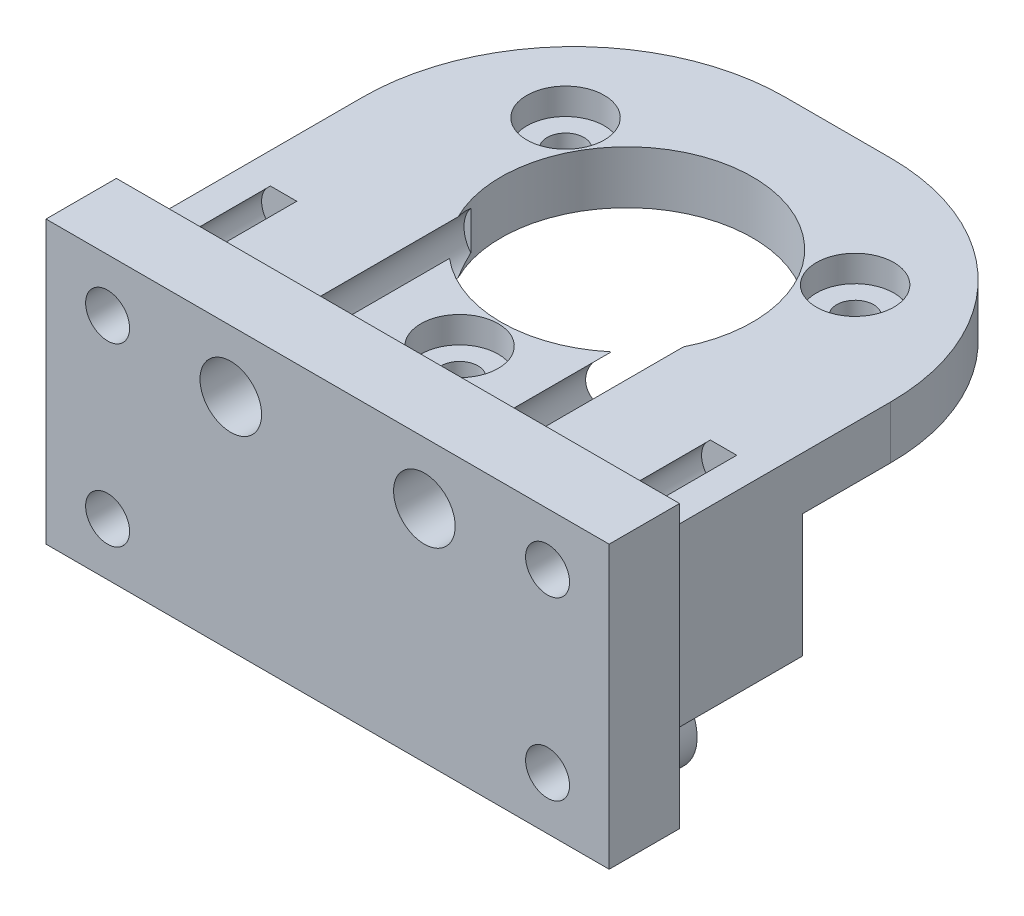
from build123d import *

# Parameters (mm, degrees)
SKETCH1_W                = 30
SKETCH1_H                = 10
MAIN_DEPTH               = 25
SKETCH5_R                = 1.05
SKETCH5_R_2              = 7.15
MAINANDFIXHOLE_DEPTH     = 11
SKETCH6_R                = 2.2
CODERFIXHOLE2_DEPTH      = 1.5
CODERHOLE2_DEPTH         = 7
SKETCH10_W               = 32
SKETCH10_H               = 16
LINK_DEPTH               = 4
SKETCH8_R                = 1.25
VERTICALHOLES_DEPTH      = 10
HOLELPATTERN1_COUNT      = 2
HOLELPATTERN1_PITCH      = 25
HOLELPATTERN1_COUNT_DIR2 = 2
HOLELPATTERN1_PITCH_DIR2 = 10
SKETCH13_R               = 2.5
LINKREINFORCEMENT_DEPTH  = 2
FILLET6_R                = 12
SKETCH14_R               = 1.25
FIXHOLE_DEPTH            = 10
SKETCH16_R               = 1.75
HEXAKEYACCESSHOLE_DEPTH  = 15


with BuildPart() as part:
    # Sketch1 → Main (new body)
    with BuildSketch(Plane.XY):
        Rectangle(SKETCH1_W, SKETCH1_H)
    extrude(amount=MAIN_DEPTH)

    # Sketch5 → MainAndFixHole (cut, through all)
    with BuildSketch(Plane(origin=(0, -5, 0), x_dir=(-1, 0, 0), z_dir=(0, -1, 0))):
        with Locations((0, -21.5)):
            Circle(SKETCH5_R)
        with Locations((-8.227241336, -7.25)):
            Circle(SKETCH5_R)
        with Locations((8.227241336, -7.25)):
            Circle(SKETCH5_R)
        with Locations((0, -12)):
            Circle(SKETCH5_R_2)
    extrude(amount=-MAINANDFIXHOLE_DEPTH, mode=Mode.SUBTRACT)

    # Sketch6 → CoderFixHole2 (cut)
    with BuildSketch(Plane(origin=(0, 5, 0), x_dir=(-1, 0, 0), z_dir=(0, -1, 0))):
        with Locations((0, -21.5)):
            Circle(SKETCH6_R)
        with Locations((-8.227241336, -7.25)):
            Circle(SKETCH6_R)
        with Locations((8.227241336, -7.25)):
            Circle(SKETCH6_R)
    extrude(amount=CODERFIXHOLE2_DEPTH, mode=Mode.SUBTRACT)

    # Sketch11 → CoderHole2 (cut)
    with BuildSketch(Plane(origin=(0, -5, 0), x_dir=(1, 0, 0), z_dir=(0, 1, 0))):
        with BuildLine():
            Line((-15, 0), (15, 0))
            Line((15, 0), (15, -17))
            Line((15, -17), (10.908712115, -17))
            ThreePointArc((10.908712115, -17), (0, -24), (-10.908712115, -17))
            Line((-10.908712115, -17), (-15, -17))
            Line((-15, -17), (-15, 0))
        make_face()
    extrude(amount=CODERHOLE2_DEPTH, mode=Mode.SUBTRACT)

    # Sketch10 → Link (add)
    with BuildSketch(Plane.XY.offset(25)):
        with Locations((0, -1)):
            Rectangle(SKETCH10_W, SKETCH10_H)
    extrude(amount=LINK_DEPTH)

    # Sketch8 → VerticalHoles (cut)
    with BuildSketch(Plane.XY.offset(29)):
        with Locations((12.5, 4)):
            Circle(SKETCH8_R)
    verticalholes = extrude(amount=-VERTICALHOLES_DEPTH, mode=Mode.SUBTRACT)

    # HoleLPattern1: VerticalHoles 2 × 2
    with Locations(*[(-i * HOLELPATTERN1_PITCH, -j * HOLELPATTERN1_PITCH_DIR2, 0) for i in range(HOLELPATTERN1_COUNT) for j in range(HOLELPATTERN1_COUNT_DIR2) if (i, j) != (0, 0)]):
        add(verticalholes, mode=Mode.SUBTRACT)

    # Sketch13 → LinkReinforcement (add)
    with BuildSketch(Plane(origin=(0, 0, 25), x_dir=(-1, 0, 0), z_dir=(0, 0, -1))):
        with Locations((-12.5, -6)):
            Circle(SKETCH13_R)
        with Locations((12.5, -6)):
            Circle(SKETCH13_R)
    extrude(amount=LINKREINFORCEMENT_DEPTH)

    # Fillet6
    fillet6_edges = [part.edges().sort_by_distance(p)[0] for p in [
        (-15, 3.5, 0),
        (15, 3.5, 0),
    ]]
    fillet(fillet6_edges, radius=FILLET6_R)

    # Sketch14 → FixHole (cut)
    with BuildSketch(Plane.XY.offset(29)):
        with Locations((-12.5, -6)):
            Circle(SKETCH14_R)
        with Locations((12.5, -6)):
            Circle(SKETCH14_R)
    extrude(amount=-FIXHOLE_DEPTH, mode=Mode.SUBTRACT)

    # Sketch16 → HexaKeyAccessHole (cut)
    with BuildSketch(Plane.XY.offset(29)):
        with Locations((-5.5, 3.5)):
            Circle(SKETCH16_R)
        with Locations((5.5, 3.5)):
            Circle(SKETCH16_R)
    extrude(amount=-HEXAKEYACCESSHOLE_DEPTH, mode=Mode.SUBTRACT)


solid = part.part
